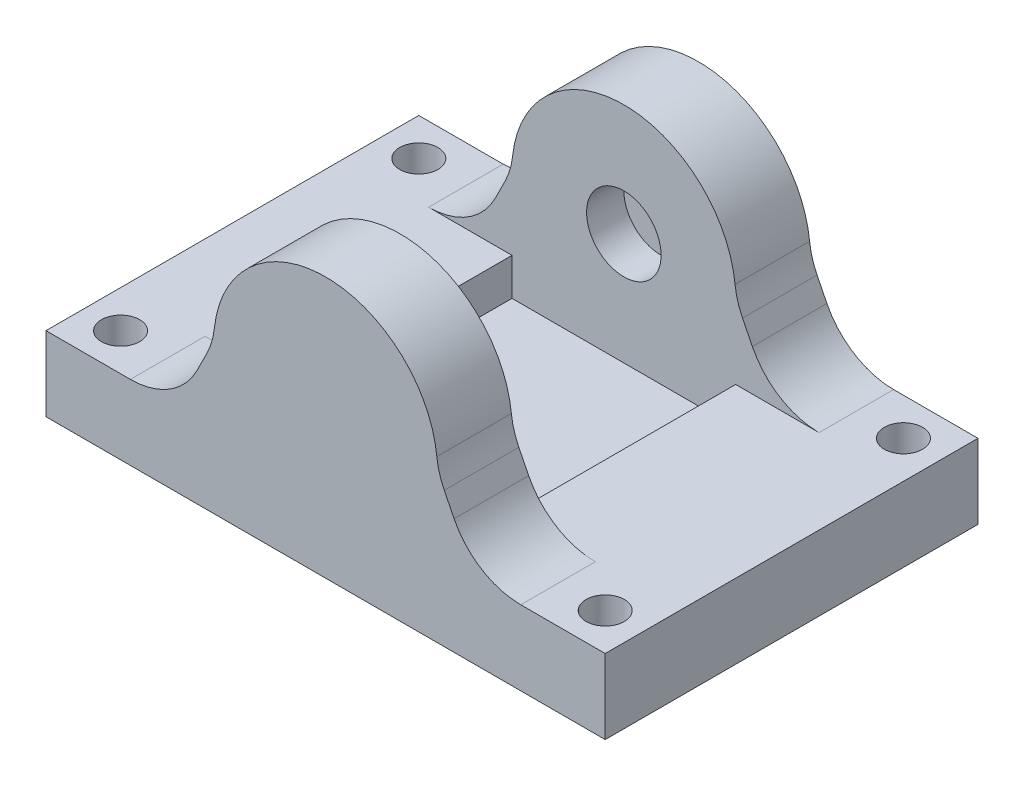
from build123d import *

# Parameters (mm, degrees)
SKETCH1_W               = 75
SKETCH1_H               = 50
BOSS_EXTRUDE1_DEPTH     = 10
BOSS_EXTRUDE2_DEPTH     = 10
FILLET1_R               = 10
SKETCH4_R               = 5
CUT_EXTRUDE1_DEPTH      = 5
FILLET1_OF_MIRROR1_R    = 10
SKETCH5_R               = 2.5625
CUT_EXTRUDE2_DEPTH      = 11
MIRROR3_COPY_1_SKETCH_R = 2.5625
MIRROR3_COPY_1_DEPTH    = 11
SKETCH6_W               = 30
SKETCH6_H               = 30
CUT_EXTRUDE3_DEPTH      = 5


with BuildPart() as part:
    # Sketch1 → Boss-Extrude1 (new body)
    with BuildSketch(Plane(origin=(0, 0, 0), x_dir=(1, 0, 0), z_dir=(0, 1, 0))):
        with Locations((37.5, 25)):
            Rectangle(SKETCH1_W, SKETCH1_H)
    extrude(amount=BOSS_EXTRUDE1_DEPTH)

    # Sketch2 → Boss-Extrude2 (add)
    with BuildSketch(Plane.XY):
        with BuildLine():
            Line((52.5, 20), (57.5, 10))
            Line((57.5, 10), (17.5, 10))
            Line((17.5, 10), (22.5, 20))
            ThreePointArc((22.5, 20), (37.5, 35), (52.5, 20))
        make_face()
    boss_extrude2 = extrude(amount=-BOSS_EXTRUDE2_DEPTH)

    # Fillet1
    fillet1_edges = [part.edges().sort_by_distance(p)[0] for p in [
        (22.5, 20, -5),
        (52.5, 20, -5),
        (57.5, 10, -5),
        (17.5, 10, -5),
    ]]
    fillet(fillet1_edges, radius=FILLET1_R)

    # Sketch4 → Cut-Extrude1 (cut)
    with BuildSketch(Plane(origin=(0, 0, -10), x_dir=(-1, 0, 0), z_dir=(0, 0, -1))):
        with Locations((-37.5, 20)):
            Circle(SKETCH4_R)
    cut_extrude1 = extrude(amount=-CUT_EXTRUDE1_DEPTH, mode=Mode.SUBTRACT)

    # Mirror1: Boss-Extrude2, Cut-Extrude1 across plane
    add(boss_extrude2.mirror(Plane(origin=(0, 0, -25), x_dir=(1, 0, 0), z_dir=(0, 0, -1))))
    add(cut_extrude1.mirror(Plane(origin=(0, 0, -25), x_dir=(1, 0, 0), z_dir=(0, 0, -1))), mode=Mode.SUBTRACT)

    # Fillet1 of Mirror1
    fillet1_of_mirror1_edges = [part.edges().sort_by_distance(p)[0] for p in [
        (22.5, 20, -45),
        (52.5, 20, -45),
        (57.5, 10, -45),
        (17.5, 10, -45),
    ]]
    fillet(fillet1_of_mirror1_edges, radius=FILLET1_OF_MIRROR1_R)

    # Sketch5 → Cut-Extrude2 (cut, through all)
    with BuildSketch(Plane(origin=(0, 10, 0), x_dir=(1, 0, 0), z_dir=(0, 1, 0))):
        with Locations((5, 5)):
            Circle(SKETCH5_R)
    cut_extrude2 = extrude(amount=-CUT_EXTRUDE2_DEPTH, mode=Mode.SUBTRACT)

    # Mirror2: Cut-Extrude2 across plane
    add(cut_extrude2.mirror(Plane(origin=(0, 0, -25), x_dir=(1, 0, 0), z_dir=(0, 0, -1))), mode=Mode.SUBTRACT)

    # Mirror3: Cut-Extrude2 across plane
    add(cut_extrude2.mirror(Plane(origin=(37.5, 0, 0), x_dir=(0, 0, 1), z_dir=(1, 0, 0))), mode=Mode.SUBTRACT)

    # Mirror3 copy 1 sketch → Mirror3 copy 1 (cut, through all)
    with BuildSketch(Plane(origin=(75, 10, -50), x_dir=(-1, 0, 0), z_dir=(0, 1, 0))):
        with Locations((5, 5)):
            Circle(MIRROR3_COPY_1_SKETCH_R)
    extrude(amount=-MIRROR3_COPY_1_DEPTH, mode=Mode.SUBTRACT)

    # Sketch6 → Cut-Extrude3 (cut)
    with BuildSketch(Plane(origin=(0, 10, 0), x_dir=(1, 0, 0), z_dir=(0, 1, 0))):
        with Locations((37.5, 25)):
            Rectangle(SKETCH6_W, SKETCH6_H)
    extrude(amount=-CUT_EXTRUDE3_DEPTH, mode=Mode.SUBTRACT)


solid = part.part
